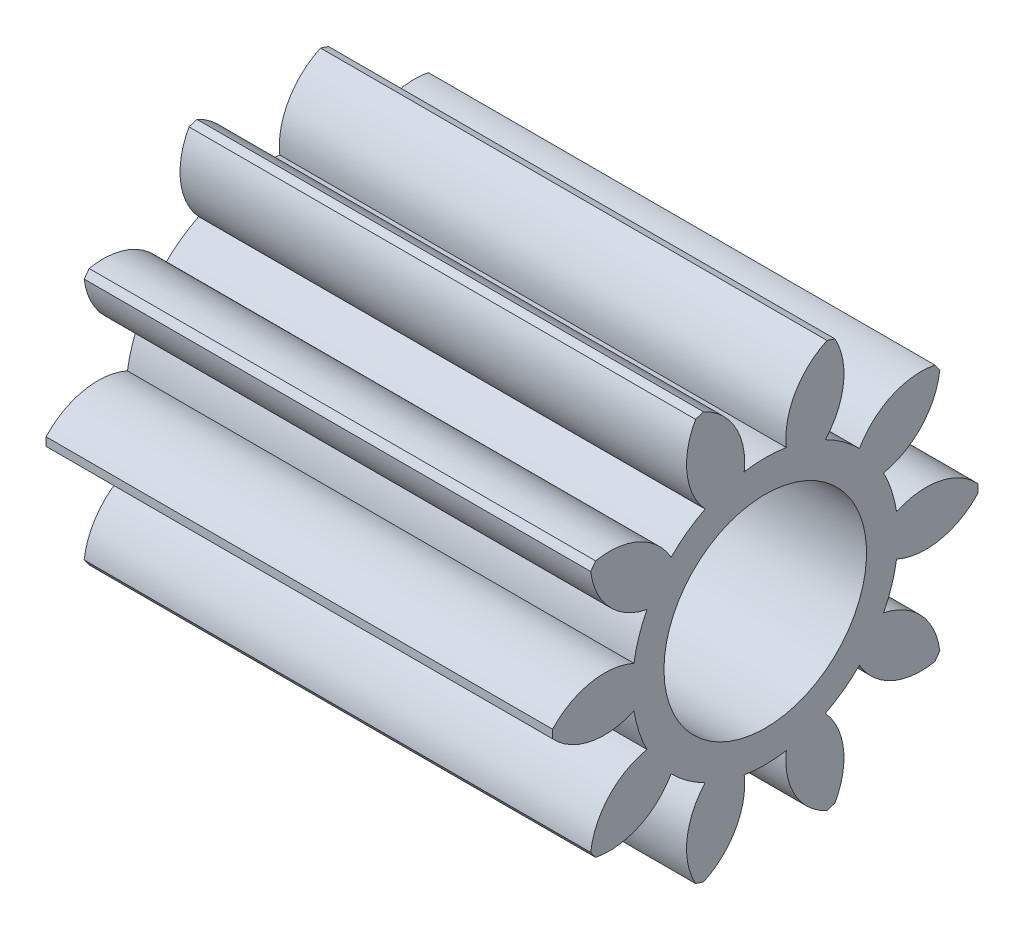
from build123d import *

# Parameters (mm, degrees)
BASPROSKE_W     = 10
BASPROSKE_H     = 4.2
TOOTHCUT_DEPTH  = 12.630993079
TEETHCUTS_COUNT = 10
TEETHCUTS_ANGLE = 324
BORSKE_R        = 2
BORE_DEPTH      = 50.0000508


with BuildPart() as part:
    # BasProSke → Base-Revolve (revolve)
    with BuildSketch(Plane(origin=(0, 0, 0), x_dir=(1, 0, 0), z_dir=(0, 1, 0)), mode=Mode.PRIVATE) as base_revolve_sk:
        with Locations((5, 2.1)):
            Rectangle(BASPROSKE_W, BASPROSKE_H)
    revolve(base_revolve_sk.sketch.rotate(Axis((-10, 0, 0), (1, 0, 0)), 180), axis=Axis((-10, 0, 0), (1, 0, 0)))

    # TooCutSke → ToothCut (cut, through all)
    with BuildSketch(Plane(origin=(0, 0, 0), x_dir=(0, 0, -1), z_dir=(1, 0, 0))):
        with BuildLine():
            ThreePointArc((0.415506654, 2.590893711), (0, 2.624), (-0.415506654, 2.590893711))
            ThreePointArc((-0.415506654, 2.590893711), (-0.596160737, 3.451685568), (-1.254578949, 4.034852763))
            ThreePointArc((-1.254578949, 4.034852763), (0, 4.2254), (1.254578949, 4.034852763))
            ThreePointArc((1.254578949, 4.034852763), (0.596160737, 3.451685568), (0.415506654, 2.590893711))
        make_face()
    toothcut = extrude(amount=TOOTHCUT_DEPTH, mode=Mode.SUBTRACT)

    # TeethCuts: ToothCut ×10 about axis
    teethcuts_axis = Axis((-10, 0, 0), (1, 0, 0))
    for i in range(1, TEETHCUTS_COUNT):
        add(toothcut.rotate(teethcuts_axis, i * TEETHCUTS_ANGLE / (TEETHCUTS_COUNT - 1)), mode=Mode.SUBTRACT)

    # BorSke → Bore (cut, symmetric)
    with BuildSketch(Plane(origin=(0, 0, 0), x_dir=(0, 0, -1), z_dir=(1, 0, 0))):
        with Locations(Location((0, 0, 0), (0, 0, 180))):
            Circle(BORSKE_R)
    extrude(amount=BORE_DEPTH, both=True, mode=Mode.SUBTRACT)


solid = part.part
